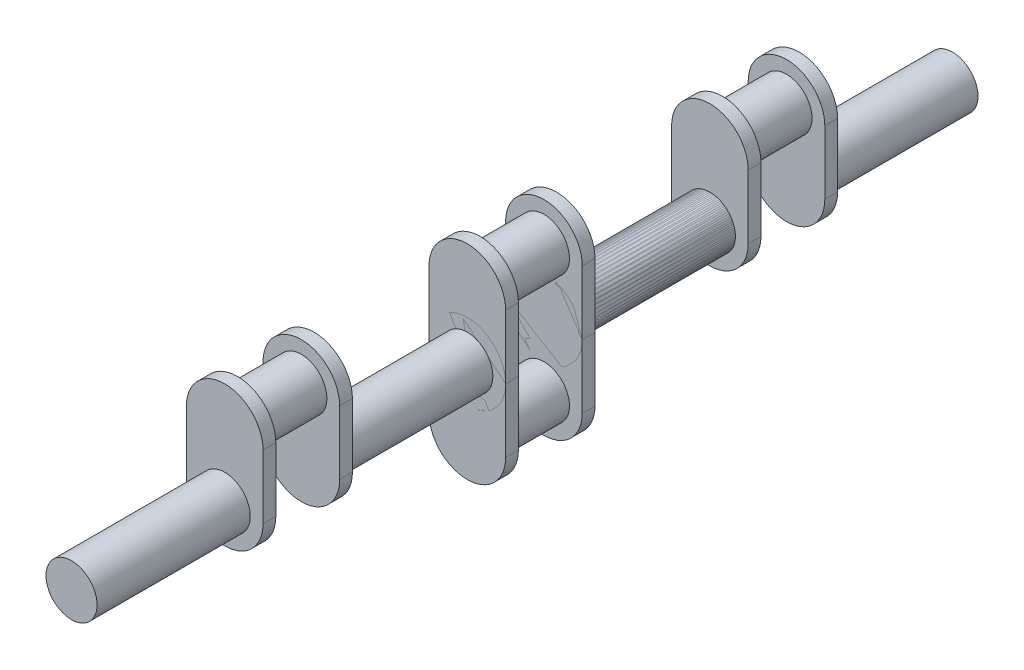
from build123d import *

# Parameters (mm, degrees)
SKETCH1_R           = 10
BOSS_EXTRUDE1_DEPTH = 60
BOSS_EXTRUDE2_DEPTH = 5
SKETCH4_R           = 10
BOSS_EXTRUDE3_DEPTH = 25
LPATTERN2_COUNT     = 3
LPATTERN2_PITCH     = 95
SKETCH7_R           = 10
BOSS_EXTRUDE5_DEPTH = 60


with BuildPart() as part:
    # Sketch1 → Boss-Extrude1 (new body)
    with BuildSketch(Plane.XY):
        Circle(SKETCH1_R)
    extrude(amount=BOSS_EXTRUDE1_DEPTH)

    # Sketch2 → Boss-Extrude2 (add)
    with BuildSketch(Plane.XY.offset(60)):
        with BuildLine():
            Line((-15, 25), (-15, 0))
            ThreePointArc((-15, 0), (0, -15), (15, 0))
            Line((15, 0), (15, 25))
            ThreePointArc((15, 25), (0, 40), (-15, 25))
        make_face()
    boss_extrude2 = extrude(amount=BOSS_EXTRUDE2_DEPTH)

    # Sketch4 → Boss-Extrude3 (add)
    with BuildSketch(Plane.XY.offset(65)):
        with Locations((0, 25)):
            Circle(SKETCH4_R)
    extrude(amount=BOSS_EXTRUDE3_DEPTH)

    # Mirror1: Boss-Extrude2 across plane
    add(boss_extrude2.mirror(Plane.XY.offset(77.5)))


with BuildPart() as lpattern2_1:
    # LPattern2: pattern copy
    add(part.part.moved(Location(Vector(0, 0, 1) * (1 * LPATTERN2_PITCH))))


with BuildPart() as lpattern2_2:
    # LPattern2: pattern copy
    add(part.part.moved(Location(Vector(0, 0, 1) * (2 * LPATTERN2_PITCH))))

    # Sketch7 → Boss-Extrude5 (add)
    with BuildSketch(Plane.XY.offset(285)):
        Circle(SKETCH7_R)
    extrude(amount=BOSS_EXTRUDE5_DEPTH)


with BuildPart() as body_4:
    # Mirror2: mirrored copy
    add(lpattern2_1.part.mirror(Plane.ZX))


with BuildPart() as part_1:
    add(part.part)

    # Combine1: union LPattern2_2, body 4
    add(lpattern2_2.part)
    add(body_4.part)


solid = Compound([lpattern2_1.part, part_1.part])
